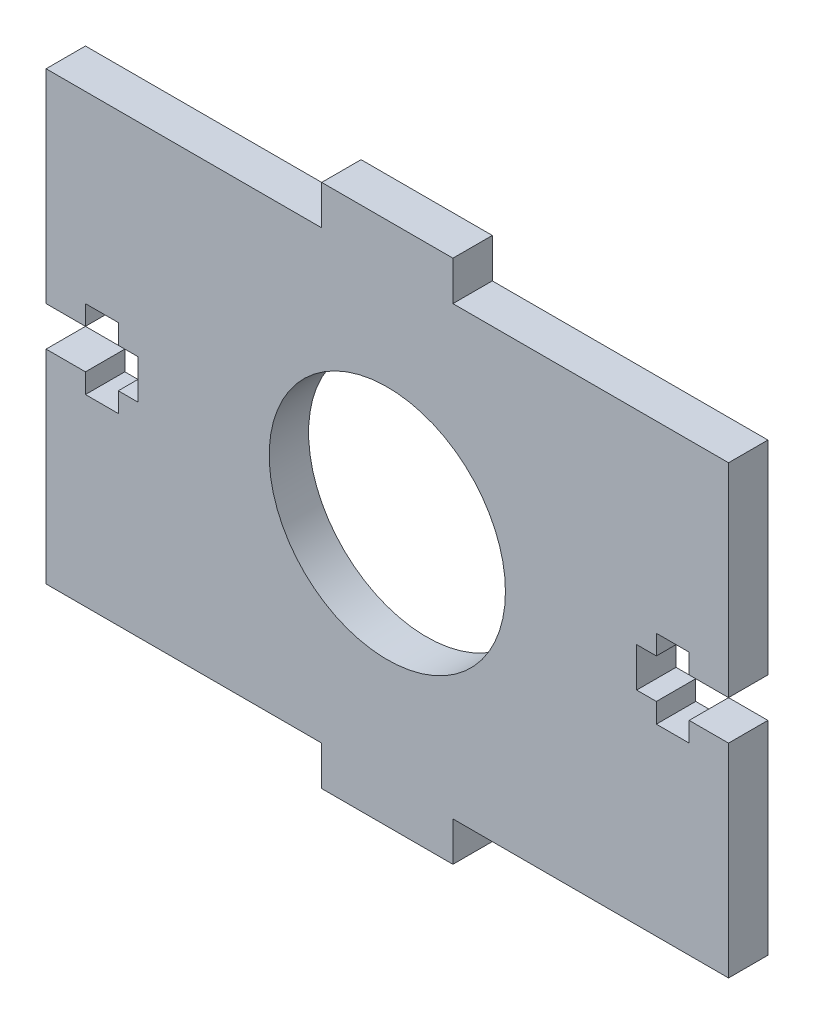
from build123d import *

# Parameters (mm, degrees)
SKETCH1_R           = 9
BOSS_EXTRUDE1_DEPTH = 3


with BuildPart() as part:
    # Sketch1 → Boss-Extrude1 (new body)
    with BuildSketch(Plane.XY):
        Polygon((-26, -17), (-5, -17), (-5, -20), (5, -20), (5, -17), (26, -17), (26, -1.5), (23, -1.5), (23, -3), (20.5, -3), (20.5, -1.5), (19, -1.5), (19, 1.5), (20.5, 1.5), (20.5, 3), (23, 3), (23, 1.5), (26, 1.5), (26, 17), (5, 17), (5, 20), (-5, 20), (-5, 17), (-26, 17), (-26, 1.5), (-23, 1.5), (-23, 3), (-20.5, 3), (-20.5, 1.5), (-19, 1.5), (-19, -1.5), (-20.5, -1.5), (-20.5, -3), (-23, -3), (-23, -1.5), (-26, -1.5), align=None)
        Circle(SKETCH1_R, mode=Mode.SUBTRACT)
    extrude(amount=BOSS_EXTRUDE1_DEPTH)


solid = part.part
